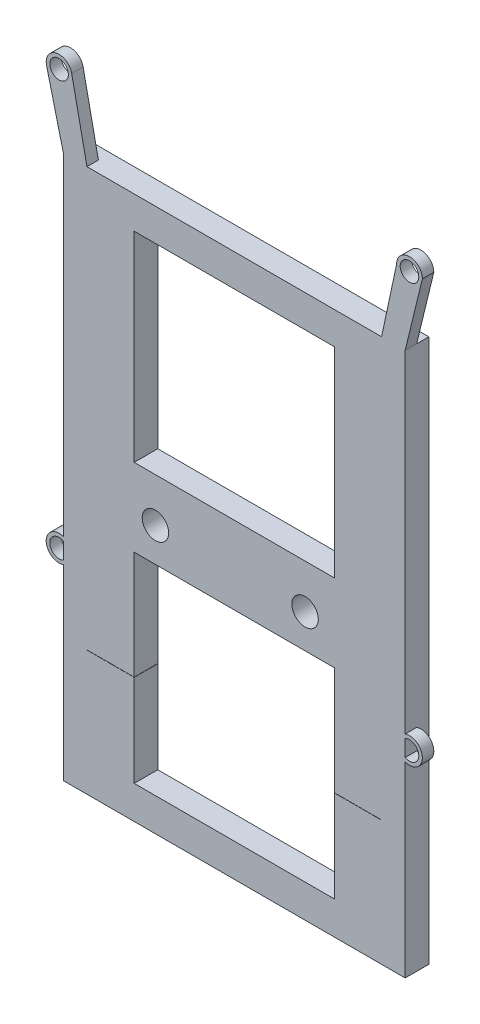
from build123d import *

# Parameters (mm, degrees)
SKETCH_1_R          = 1.85
EXTRUDE_1_DEPTH     = 3.3
SKETCH_2_W          = 3.3
SKETCH_2_H          = 58.544472475
EXTRUDE_2_DEPTH     = 3.3
EXTRUDE_2_2_DEPTH   = 3.3
SKETCH_3_W          = 47.8
SKETCH_3_H          = 17.46
EXTRUDE_3_DEPTH     = 3.3
SKETCH_4_W          = 28
SKETCH_4_H          = 28
CUT_EXTRUDE_2_DEPTH = 3.3
SKETCH_5_R          = 1.8
SKETCH_5_R_2        = 1.3
EXTRUDE_4_DEPTH     = 1.6


with BuildPart() as part:
    # 草圖1 → 填料-伸長1 (new body)
    with BuildSketch(Plane.XY):
        Polygon((21.926158038, 28.738964578), (21.926158038, -28.626702997), (-19.273841962, -28.626702997), (-19.273841962, 28.738964578), (-19.273841962, 29.888964578), (21.926158038, 29.888964578), align=None)
        with Locations((11.226158038, -8.761035422)):
            Circle(SKETCH_1_R, mode=Mode.SUBTRACT)
        with Locations((-9.7, -8.761035422)):
            Circle(SKETCH_1_R, mode=Mode.SUBTRACT)
    extrude(amount=-EXTRUDE_1_DEPTH)


with BuildPart() as body_2:
    # 草圖2 → 填料-伸長2 (new body)
    with BuildSketch(Plane.XY):
        with Locations((23.576158038, 0.61672834)):
            Rectangle(SKETCH_2_W, SKETCH_2_H)
    extrude(amount=-EXTRUDE_2_DEPTH)



with BuildPart() as body_3:
    # 草圖2 → Extrude 2 2 (new body)
    with BuildSketch(Plane.XY):
        with Locations((-20.923841962, 0.61672834)):
            Rectangle(SKETCH_2_W, SKETCH_2_H)
    extrude(amount=-EXTRUDE_2_2_DEPTH)


with BuildPart() as body_2_1:
    add(body_2.part)

    add(body_3.part)  # 填料-伸長3 merges body 3
    # 草圖3 → 填料-伸長3 (add)
    with BuildSketch(Plane.XY):
        with Locations((1.326158038, -37.385507897)):
            Rectangle(SKETCH_3_W, SKETCH_3_H)
    extrude(amount=-EXTRUDE_3_DEPTH)


with BuildPart() as cut_extrude_2_tool:
    # 草圖4 → 除料-伸長2 (new body)
    with BuildSketch(Plane.XY):
        with Locations((1.326158038, -27.495005481)):
            Rectangle(SKETCH_4_W, SKETCH_4_H)
        with Locations((1.326158038, 11.379364932)):
            Rectangle(SKETCH_4_W, SKETCH_4_H)
    extrude(amount=-CUT_EXTRUDE_2_DEPTH)


with BuildPart() as part_1:
    add(part.part)

    # 除料-伸長2: cut by cut_extrude_2_tool
    add(cut_extrude_2_tool.part, mode=Mode.SUBTRACT)



with BuildPart() as body_2_2:
    add(body_2_1.part)

    # 除料-伸長2: cut by cut_extrude_2_tool
    add(cut_extrude_2_tool.part, mode=Mode.SUBTRACT)


with BuildPart() as part_2:
    add(part_1.part)

    add(body_2_2.part)  # 填料-伸長4 merges body 2
    # 草圖5 → 填料-伸長4 (add)
    with BuildSketch(Plane.XY):
        with Locations((-23.173841962, 39.740306118)):
            Circle(SKETCH_5_R)
        with Locations((-23.173841962, 39.740306118)):
            Circle(SKETCH_5_R_2, mode=Mode.SUBTRACT)
        with BuildLine():
            Line((-24.920422623, 39.305040689), (-22.573841962, 29.888964578))
            Line((-22.573841962, 29.888964578), (-19.273841962, 29.888964578))
            Line((-19.273841962, 29.888964578), (-21.411987289, 40.108909035))
            ThreePointArc((-21.411987289, 40.108909035), (-21.38340369, 39.925591827), (-21.373841962, 39.740306118))
            ThreePointArc((-21.373841962, 39.740306118), (-22.954576359, 37.953710866), (-24.920422623, 39.305040689))
        make_face()
        with BuildLine():
            ThreePointArc((27.626158038, 39.740306118), (25.826158038, 41.540306118), (24.026158038, 39.740306118))
            ThreePointArc((24.026158038, 39.740306118), (25.400100428, 37.991456521), (27.424463497, 38.912405363))
            Line((27.424463497, 38.912405363), (27.626158038, 39.740306118))
        make_face()
        with Locations((25.826158038, 39.740306118)):
            Circle(SKETCH_5_R_2, mode=Mode.SUBTRACT)
        with BuildLine():
            ThreePointArc((27.424463497, 38.912405363), (25.400100428, 37.991456521), (24.026158038, 39.740306118))
            Line((24.026158038, 39.740306118), (21.926158038, 29.888964578))
            Line((21.926158038, 29.888964578), (25.226158038, 29.888964578))
            Line((25.226158038, 29.888964578), (27.424463497, 38.912405363))
        make_face()
        with Locations((-23.173841962, -18.259693882)):
            Circle(SKETCH_5_R)
        with Locations((-23.173841962, -18.259693882)):
            Circle(SKETCH_5_R_2, mode=Mode.SUBTRACT)
        with Locations((25.826158038, -18.259693882)):
            Circle(SKETCH_5_R)
        with Locations((25.826158038, -18.259693882)):
            Circle(SKETCH_5_R_2, mode=Mode.SUBTRACT)
    extrude(amount=-EXTRUDE_4_DEPTH)


solid = part_2.part
